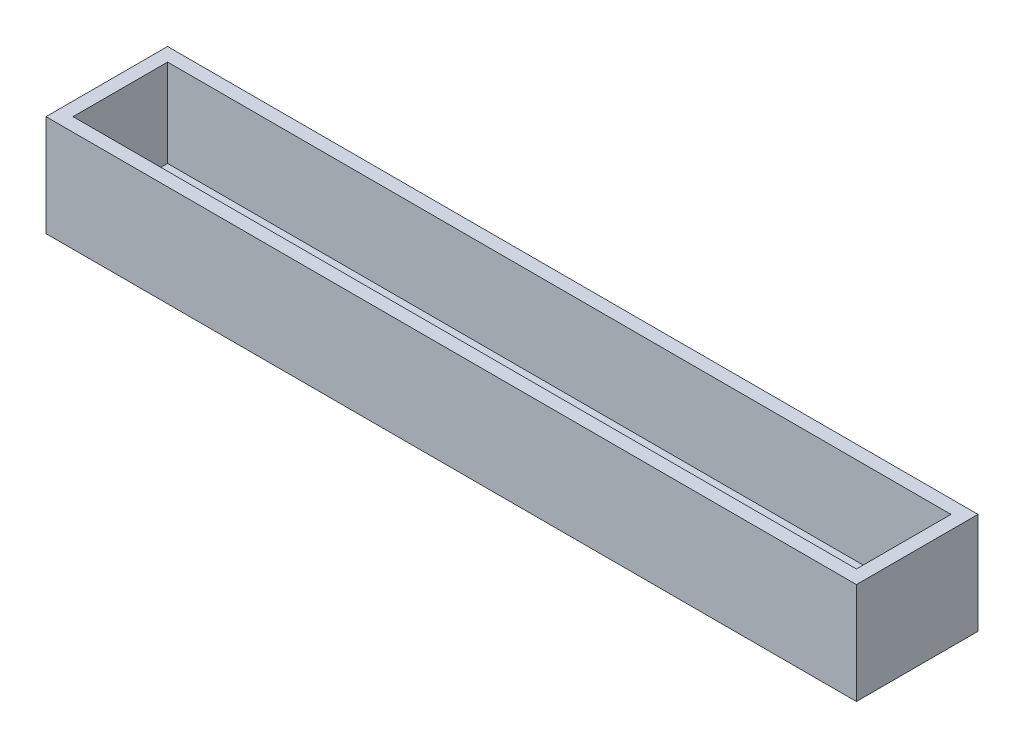
from build123d import *

# Parameters (mm, degrees)
ESQUISSE1_W             = 60
ESQUISSE1_H             = 9
BOSS_EXTRU_1_DEPTH      = 1
ESQUISSE2_W             = 60
ESQUISSE2_H             = 9
ESQUISSE2_W_2           = 58
ESQUISSE2_H_2           = 7
BOSS_EXTRU_2_DEPTH      = 6.5
ESQUISSE3_W             = 52
ESQUISSE3_H             = 3
ENL_V_MAT_EXTRU_1_DEPTH = 8.5


with BuildPart() as part:
    # Esquisse1 → Boss.-Extru.1 (new body)
    with BuildSketch(Plane(origin=(0, 0, 0), x_dir=(1, 0, 0), z_dir=(0, 1, 0))):
        with Locations((30, 4.5)):
            Rectangle(ESQUISSE1_W, ESQUISSE1_H)
    extrude(amount=BOSS_EXTRU_1_DEPTH)

    # Esquisse2 → Boss.-Extru.2 (add)
    with BuildSketch(Plane(origin=(0, 1, 0), x_dir=(1, 0, 0), z_dir=(0, 1, 0))):
        with Locations((30, 4.5)):
            Rectangle(ESQUISSE2_W, ESQUISSE2_H)
        with Locations((30, 4.5)):
            Rectangle(ESQUISSE2_W_2, ESQUISSE2_H_2, mode=Mode.SUBTRACT)
    extrude(amount=BOSS_EXTRU_2_DEPTH)

    # Esquisse3 → Enlèv. mat.-Extru.1 (cut, through all)
    with BuildSketch(Plane.XZ):
        with Locations((30, -4.5)):
            Rectangle(ESQUISSE3_W, ESQUISSE3_H)
    extrude(amount=-ENL_V_MAT_EXTRU_1_DEPTH, mode=Mode.SUBTRACT)


solid = part.part
